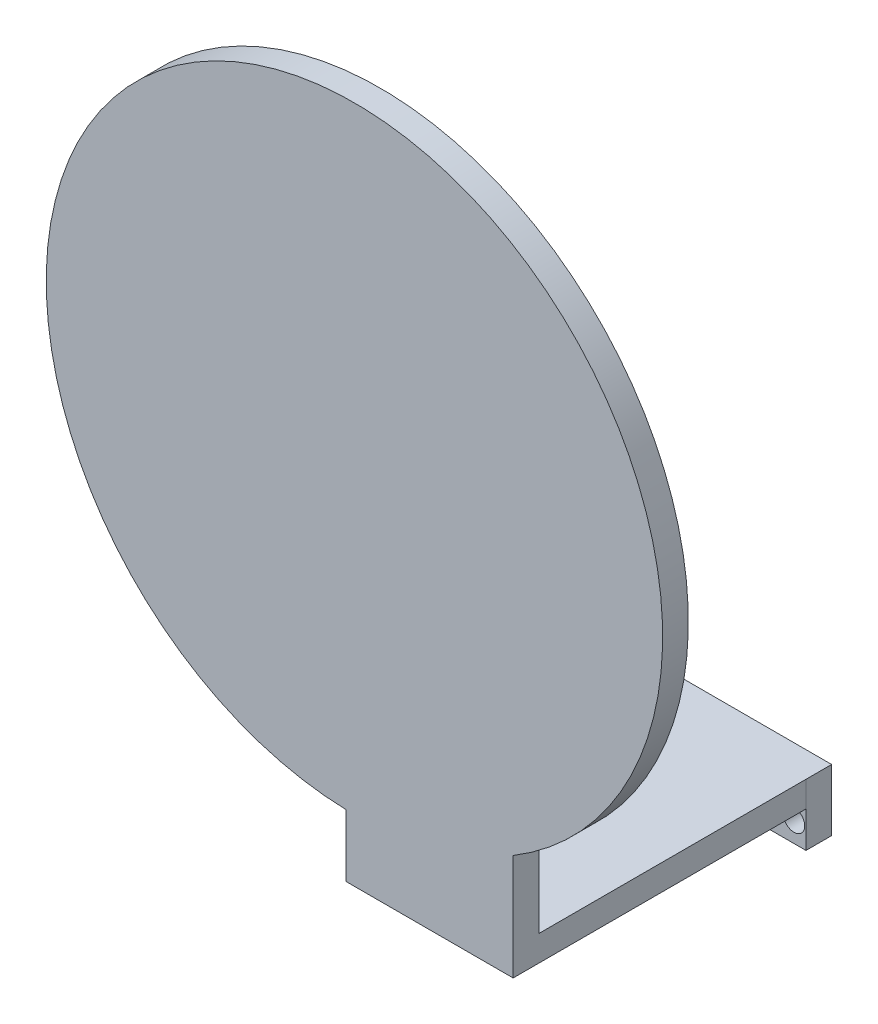
from build123d import *

# Parameters (mm, degrees)
SKETCH2_W           = 32.54
SKETCH2_H           = 8
SKETCH2_R           = 2.1
BOSS_EXTRUDE1_DEPTH = 5
SKETCH3_W           = 32.54
SKETCH3_H           = 5
BOSS_EXTRUDE2_DEPTH = 4
SKETCH4_W           = 32.539746062
SKETCH4_H           = 5
BOSS_EXTRUDE3_DEPTH = 57
SKETCH5_W           = 32.539746062
SKETCH5_H           = 5
BOSS_EXTRUDE4_DEPTH = 27.5
SKETCH7_R           = 60
BOSS_EXTRUDE6_DEPTH = 5


with BuildPart() as part:
    # Sketch2 → Boss-Extrude1 (new body)
    with BuildSketch(Plane.XY.offset(-25141.064740445)):
        with Locations((360.568878819, -3596.065695557)):
            Rectangle(SKETCH2_W, SKETCH2_H)
        with Locations((374.501060255, -3596.060789622)):
            Circle(SKETCH2_R, mode=Mode.SUBTRACT)
        with Locations((358.013502112, -3596.060789622)):
            Circle(SKETCH2_R, mode=Mode.SUBTRACT)
    extrude(amount=BOSS_EXTRUDE1_DEPTH)

    # Sketch3 → Boss-Extrude2 (add)
    with BuildSketch(Plane(origin=(0, -3592.065695557, 0), x_dir=(1, 0, 0), z_dir=(0, 1, 0))):
        with Locations((360.568878819, 25138.564740445)):
            Rectangle(SKETCH3_W, SKETCH3_H)
    extrude(amount=BOSS_EXTRUDE2_DEPTH)

    # Sketch4 → Boss-Extrude3 (add)
    with BuildSketch(Plane.XY.offset(-25136.064740445)):
        with Locations((360.56875185, -3590.565695557)):
            Rectangle(SKETCH4_W, SKETCH4_H)
    extrude(amount=BOSS_EXTRUDE3_DEPTH)

    # Sketch5 → Boss-Extrude4 (add)
    with BuildSketch(Plane(origin=(0, -3588.065695557, 0), x_dir=(1, 0, 0), z_dir=(0, 1, 0))):
        with Locations((360.56875185, 25081.564740445)):
            Rectangle(SKETCH5_W, SKETCH5_H)
    extrude(amount=BOSS_EXTRUDE4_DEPTH)

    # Sketch7 → Boss-Extrude6 (add)
    with BuildSketch(Plane.XY.offset(-25079.064740445)):
        with Locations((345.94627105, -3520.972176103)):
            Circle(SKETCH7_R)
    extrude(amount=-BOSS_EXTRUDE6_DEPTH)


solid = part.part
